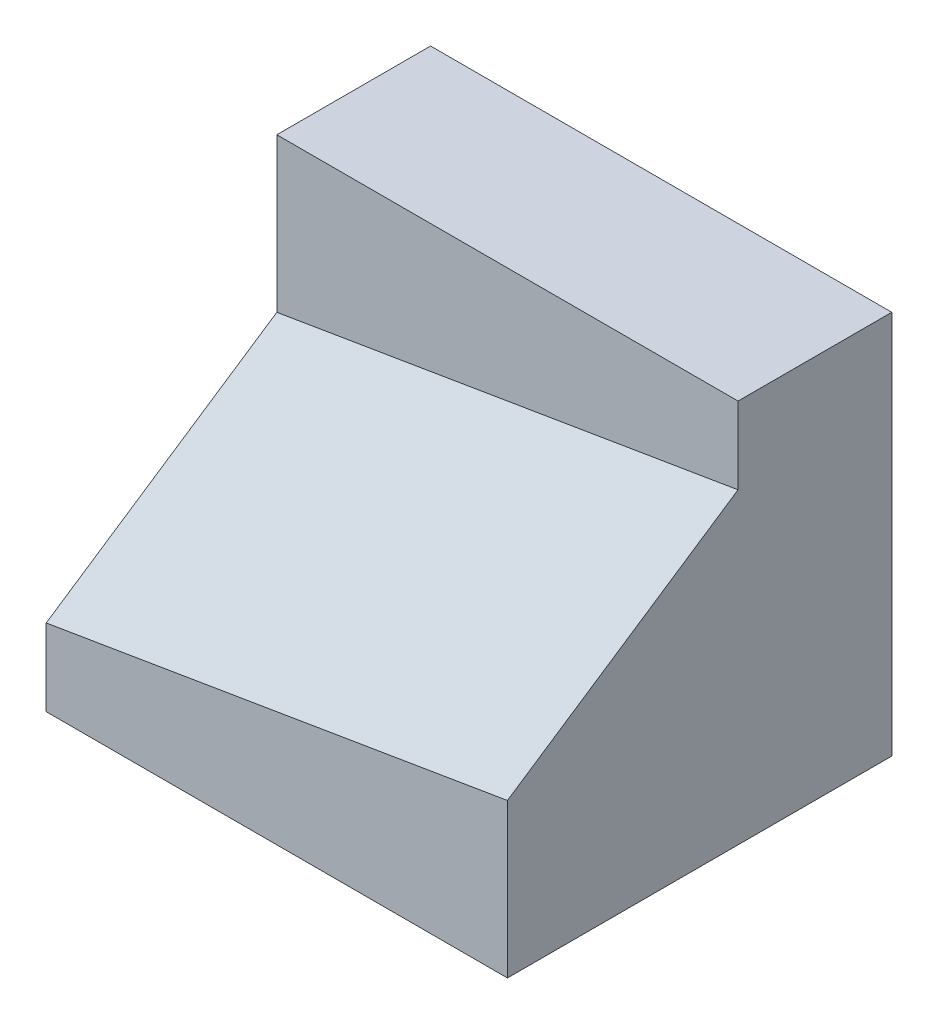
from build123d import *

# Parameters (mm, degrees)
SKETCH1_W           = 30
SKETCH1_H           = 25
BOSS_EXTRUDE1_DEPTH = 25
CUT_EXTRUDE4_DEPTH  = 25


with BuildPart() as part:
    # Sketch1 → Boss-Extrude1 (new body)
    with BuildSketch(Plane.XY):
        with Locations((-15, 12.5)):
            Rectangle(SKETCH1_W, SKETCH1_H)
    extrude(amount=BOSS_EXTRUDE1_DEPTH)

    # 3DSketch1 → Cut-Extrude4 (cut, along a direction that is not the sketch's normal)
    with BuildSketch(Plane(origin=(-30, 15, 10), x_dir=(0.8846517369293828, -0.14744195615489716, 0.4423258684646914), z_dir=(0.13736056394868915, -0.824163383692134, -0.5494422557947564))):
        Polygon((0, 0), (25.802342327, -16.100904646), (33.911649916, 0), (8.109307589, 16.100904646), align=None)
    extrude(amount=-CUT_EXTRUDE4_DEPTH, dir=(0, -1, 0), mode=Mode.SUBTRACT)


solid = part.part
